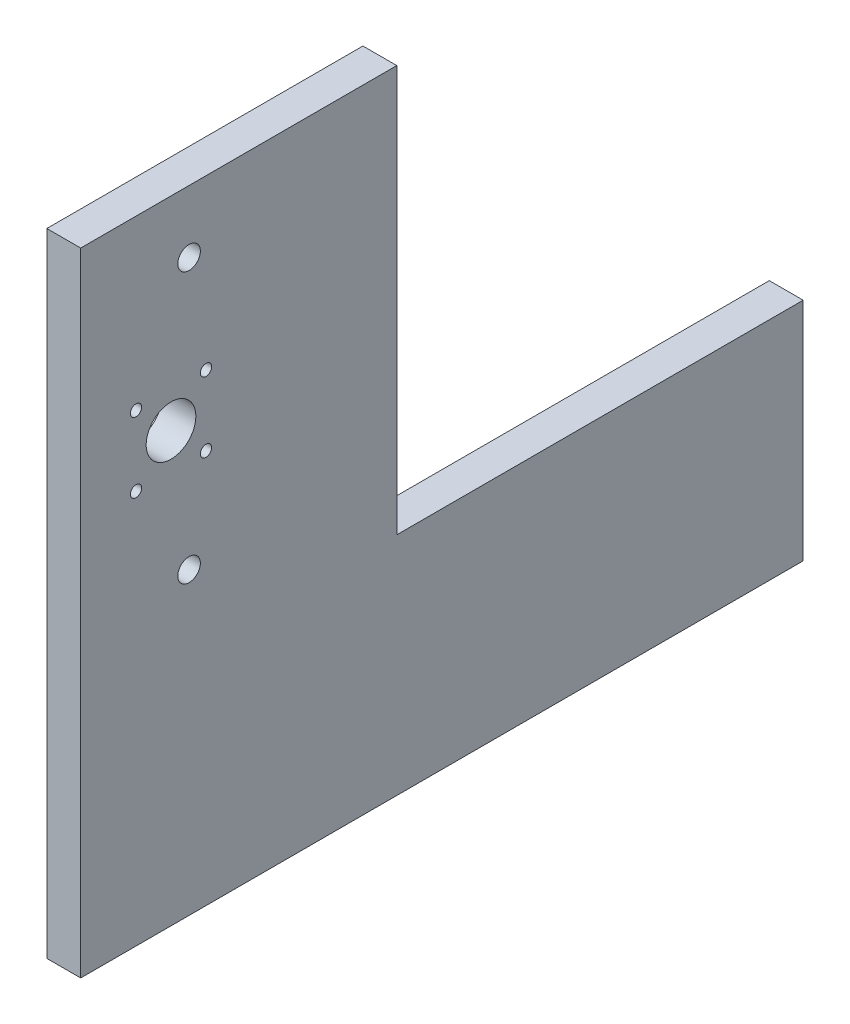
from build123d import *

# Parameters (mm, degrees)
SIDE_SKETCH_R       = 11
SIDE_SKETCH_R_2     = 2.5
SIDE_SKETCH_R_3     = 5
BOSS_EXTRUDE1_DEPTH = 15


with BuildPart() as part:
    # side sketch → Boss-Extrude1 (new body)
    with BuildSketch(Plane(origin=(0, 0, 0), x_dir=(0, 0, -1), z_dir=(1, 0, 0))):
        Polygon((15.128781153, -90.607159918), (15.128781153, 189.392840082), (155.128781153, 189.392840082), (155.128781153, 9.392840082), (335.128781153, 9.392840082), (335.128781153, -90.607159918), align=None)
        with Locations((55.128781153, 99.392840082)):
            Circle(SIDE_SKETCH_R, mode=Mode.SUBTRACT)
        with Locations((39.628781153, 114.892840082)):
            Circle(SIDE_SKETCH_R_2, mode=Mode.SUBTRACT)
        with Locations((70.628781153, 114.892840082)):
            Circle(SIDE_SKETCH_R_2, mode=Mode.SUBTRACT)
        with Locations((70.628781153, 83.892840082)):
            Circle(SIDE_SKETCH_R_2, mode=Mode.SUBTRACT)
        with Locations((39.628781153, 83.892840082)):
            Circle(SIDE_SKETCH_R_2, mode=Mode.SUBTRACT)
        with Locations((63.128781153, 161.769316483)):
            Circle(SIDE_SKETCH_R_3, mode=Mode.SUBTRACT)
        with Locations((63.128781153, 42.041950723)):
            Circle(SIDE_SKETCH_R_3, mode=Mode.SUBTRACT)
    extrude(amount=BOSS_EXTRUDE1_DEPTH)


solid = part.part
